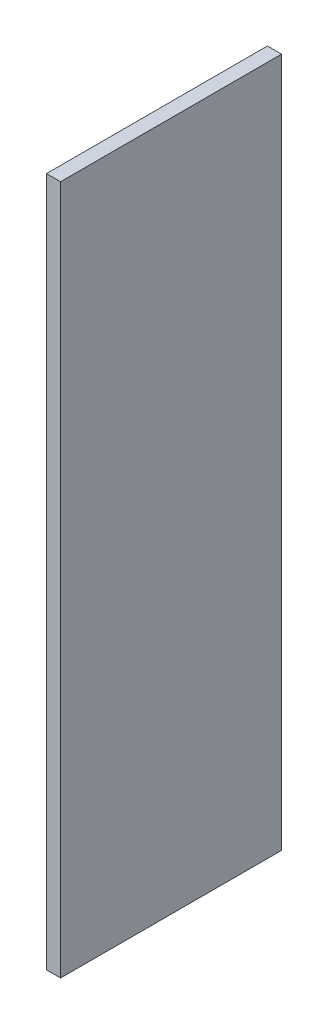
from build123d import *

# Parameters (mm, degrees)
SKETCH_1_W      = 282
SKETCH_1_H      = 880
EXTRUDE_1_DEPTH = 18


with BuildPart() as part:
    # Эскиз1 → Бобышка-Вытянуть1 (new body)
    with BuildSketch(Plane(origin=(0, 0, 0), x_dir=(0, 0, -1), z_dir=(1, 0, 0))):
        Rectangle(SKETCH_1_W, SKETCH_1_H)
    extrude(amount=EXTRUDE_1_DEPTH)


solid = part.part
